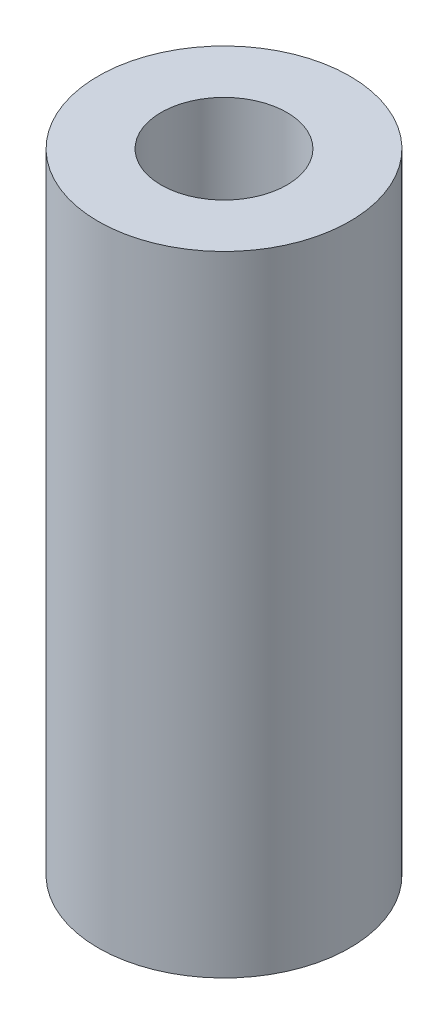
from build123d import *

# Parameters (mm, degrees)
SKETCH1_R           = 7
SKETCH1_R_2         = 3.5
BOSS_EXTRUDE1_DEPTH = 35


with BuildPart() as part:
    # Sketch1 → Boss-Extrude1 (new body)
    with BuildSketch(Plane(origin=(0, 0, 0), x_dir=(1, 0, 0), z_dir=(0, 1, 0))):
        Circle(SKETCH1_R)
        Circle(SKETCH1_R_2, mode=Mode.SUBTRACT)
    extrude(amount=BOSS_EXTRUDE1_DEPTH)


solid = part.part
